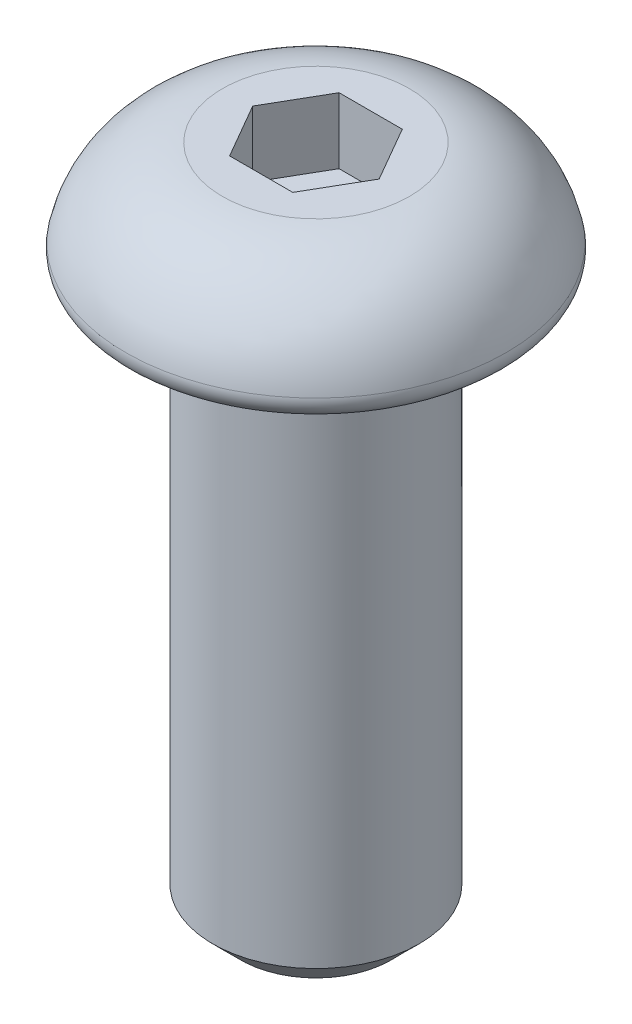
from build123d import *

# Parameters (mm, degrees)
SKETCH2_R           = 1.7526
BOSS_EXTRUDE1_DEPTH = 9.525
CUT_EXTRUDE1_DEPTH  = 1.1176
CHAMFER1_SIZE       = 0.47244
FILLET1_R           = 0.316308646


with BuildPart() as part:
    # Sketch1 → Revolve1 (revolve)
    with BuildSketch(Plane.XY):
        with BuildLine():
            Line((1.5875, 1.8542), (0, 1.8542))
            Line((0, 1.8542), (0, 0))
            Line((0, 0), (3.270560013, 0))
            ThreePointArc((3.270560013, 0), (2.787047666, 1.252073146), (1.5875, 1.8542))
        make_face()
    revolve(axis=Axis((0, 1.8542, 0), (0, -1, 0)))

    # Sketch2 → Boss-Extrude1 (add)
    with BuildSketch(Plane.XZ):
        Circle(SKETCH2_R)
    extrude(amount=BOSS_EXTRUDE1_DEPTH)

    # Sketch3 → Cut-Extrude1 (cut)
    with BuildSketch(Plane(origin=(0, 1.8542, 0), x_dir=(-1, 0, 0), z_dir=(0, 1, 0))):
        Polygon((0.536575, -0.929375162), (1.07315, 0), (0.536575, 0.929375162), (-0.536575, 0.929375162), (-1.07315, 0), (-0.536575, -0.929375162), align=None)
    extrude(amount=-CUT_EXTRUDE1_DEPTH, mode=Mode.SUBTRACT)

    # Chamfer1
    chamfer1_edges = [part.edges().sort_by_distance(p)[0] for p in [
        (-1.7526, -9.525, 0),
    ]]
    chamfer(chamfer1_edges, length=CHAMFER1_SIZE)

    # Fillet1
    fillet1_edges = [part.edges().sort_by_distance(p)[0] for p in [
        (-3.270560013, 0, 0),
        (-1.7526, 0, 0),
    ]]
    fillet(fillet1_edges, radius=FILLET1_R)


solid = part.part
